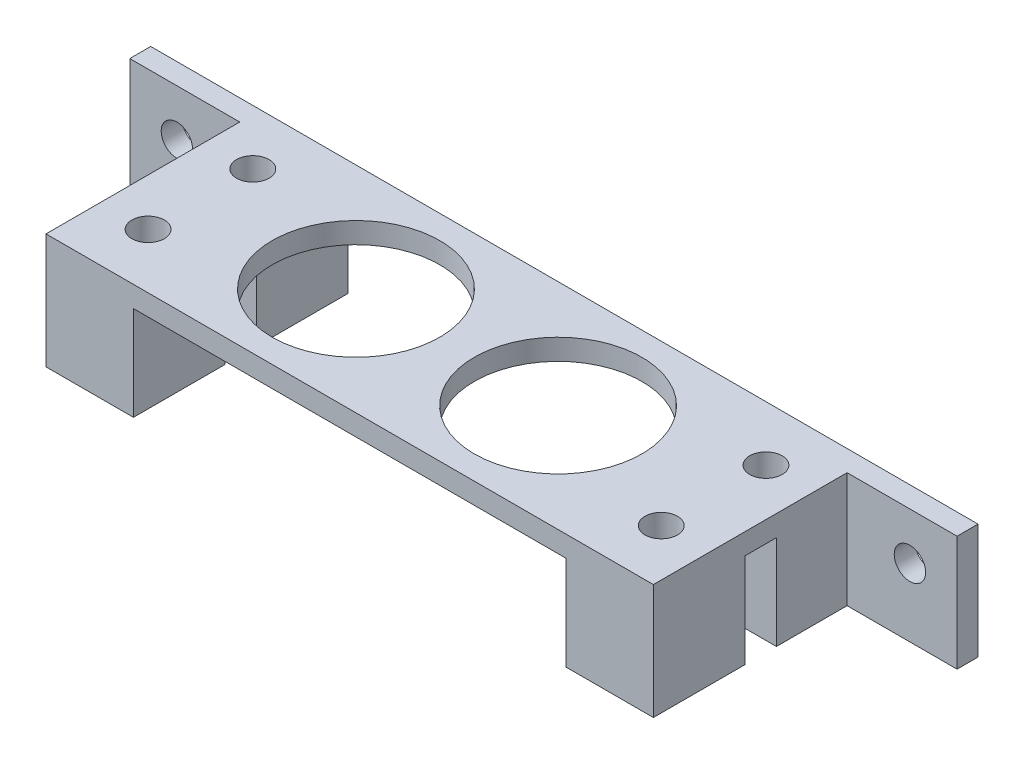
from build123d import *

# Parameters (mm, degrees)
SKETCH2_W           = 58
SKETCH2_H           = 20.5
SKETCH2_R           = 8
SKETCH2_R_2         = 1.55
BOSS_EXTRUDE1_DEPTH = 2
SKETCH3_W           = 8.35
SKETCH3_H           = 8.75
SKETCH3_R           = 1.55
BOSS_EXTRUDE2_DEPTH = 9
SKETCH4_W           = 10.5
SKETCH4_H           = 11
SKETCH4_R           = 1.5
BOSS_EXTRUDE3_DEPTH = 2


with BuildPart() as part:
    # Sketch2 → Boss-Extrude1 (new body)
    with BuildSketch(Plane(origin=(0, 0, 0), x_dir=(1, 0, 0), z_dir=(0, 1, 0))):
        Rectangle(SKETCH2_W, SKETCH2_H)
        with Locations((-9.65, 0)):
            Circle(SKETCH2_R, mode=Mode.SUBTRACT)
        with Locations((-24.5, 5)):
            Circle(SKETCH2_R_2, mode=Mode.SUBTRACT)
        with Locations((-24.5, -5)):
            Circle(SKETCH2_R_2, mode=Mode.SUBTRACT)
        with Locations((24.5, 5)):
            Circle(SKETCH2_R_2, mode=Mode.SUBTRACT)
        with Locations((24.5, -5)):
            Circle(SKETCH2_R_2, mode=Mode.SUBTRACT)
        with Locations((9.65, 0)):
            Circle(SKETCH2_R, mode=Mode.SUBTRACT)
    extrude(amount=BOSS_EXTRUDE1_DEPTH)

    # Sketch3 → Boss-Extrude2 (add)
    with BuildSketch(Plane.XZ):
        with Locations((-24.825, 5.875)):
            Rectangle(SKETCH3_W, SKETCH3_H)
        with Locations((-24.5, 5)):
            Circle(SKETCH3_R, mode=Mode.SUBTRACT)
        with Locations((-24.825, -5.875)):
            Rectangle(SKETCH3_W, SKETCH3_H)
        with Locations((-24.5, -5)):
            Circle(SKETCH3_R, mode=Mode.SUBTRACT)
        with Locations((24.825, 5.875)):
            Rectangle(SKETCH3_W, SKETCH3_H)
        with Locations((24.5, 5)):
            Circle(SKETCH3_R, mode=Mode.SUBTRACT)
        with Locations((24.825, -5.875)):
            Rectangle(SKETCH3_W, SKETCH3_H)
        with Locations((24.5, -5)):
            Circle(SKETCH3_R, mode=Mode.SUBTRACT)
    extrude(amount=BOSS_EXTRUDE2_DEPTH)

    # Sketch4 → Boss-Extrude3 (add)
    with BuildSketch(Plane(origin=(0, 0, -10.25), x_dir=(-1, 0, 0), z_dir=(0, 0, -1))):
        with Locations((34.25, -3.5)):
            Rectangle(SKETCH4_W, SKETCH4_H)
        with Locations((35, -2.5)):
            Circle(SKETCH4_R, mode=Mode.SUBTRACT)
        with Locations((-34.25, -3.5)):
            Rectangle(SKETCH4_W, SKETCH4_H)
        with Locations((-35, -2.5)):
            Circle(SKETCH4_R, mode=Mode.SUBTRACT)
    extrude(amount=-BOSS_EXTRUDE3_DEPTH)


solid = part.part
